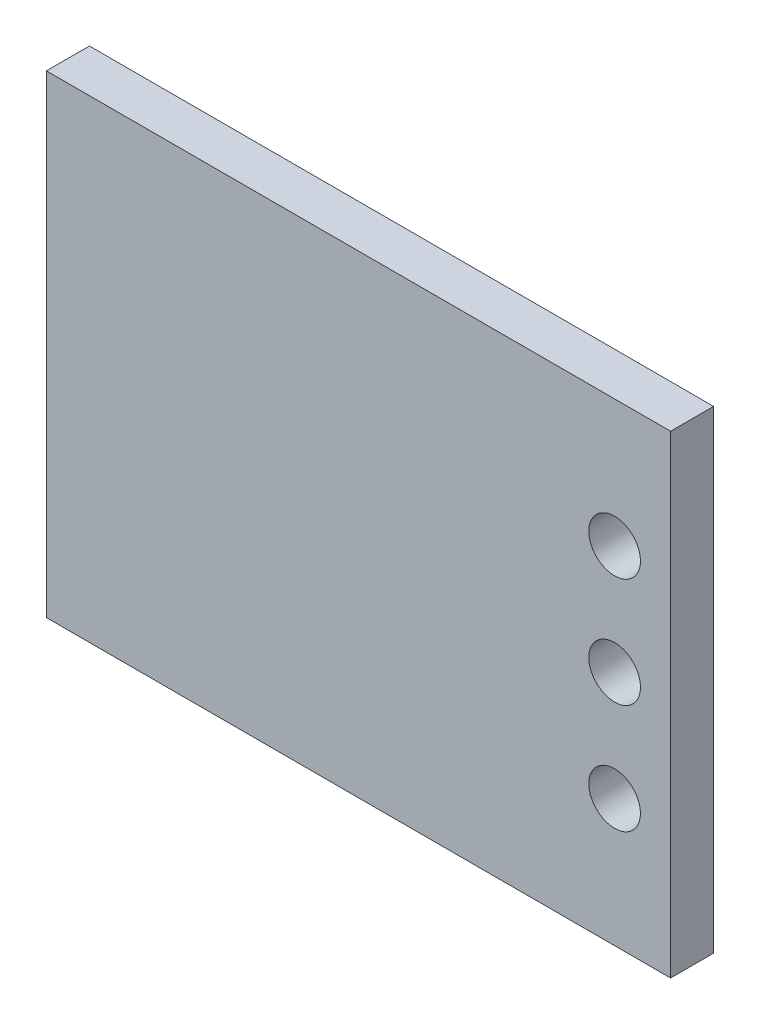
from build123d import *

# Parameters (mm, degrees)
SKETCH_1_W      = 14.5
SKETCH_1_H      = 11
SKETCH_1_R      = 0.6
EXTRUDE_1_DEPTH = 1


with BuildPart() as part:
    # Эскиз1 → Бобышка-Вытянуть1 (new body)
    with BuildSketch(Plane.XY):
        Rectangle(SKETCH_1_W, SKETCH_1_H)
        with Locations((5.95, 0)):
            Circle(SKETCH_1_R, mode=Mode.SUBTRACT)
        with Locations((5.95, 2.54)):
            Circle(SKETCH_1_R, mode=Mode.SUBTRACT)
        with Locations((5.95, -2.54)):
            Circle(SKETCH_1_R, mode=Mode.SUBTRACT)
    extrude(amount=EXTRUDE_1_DEPTH)


solid = part.part
